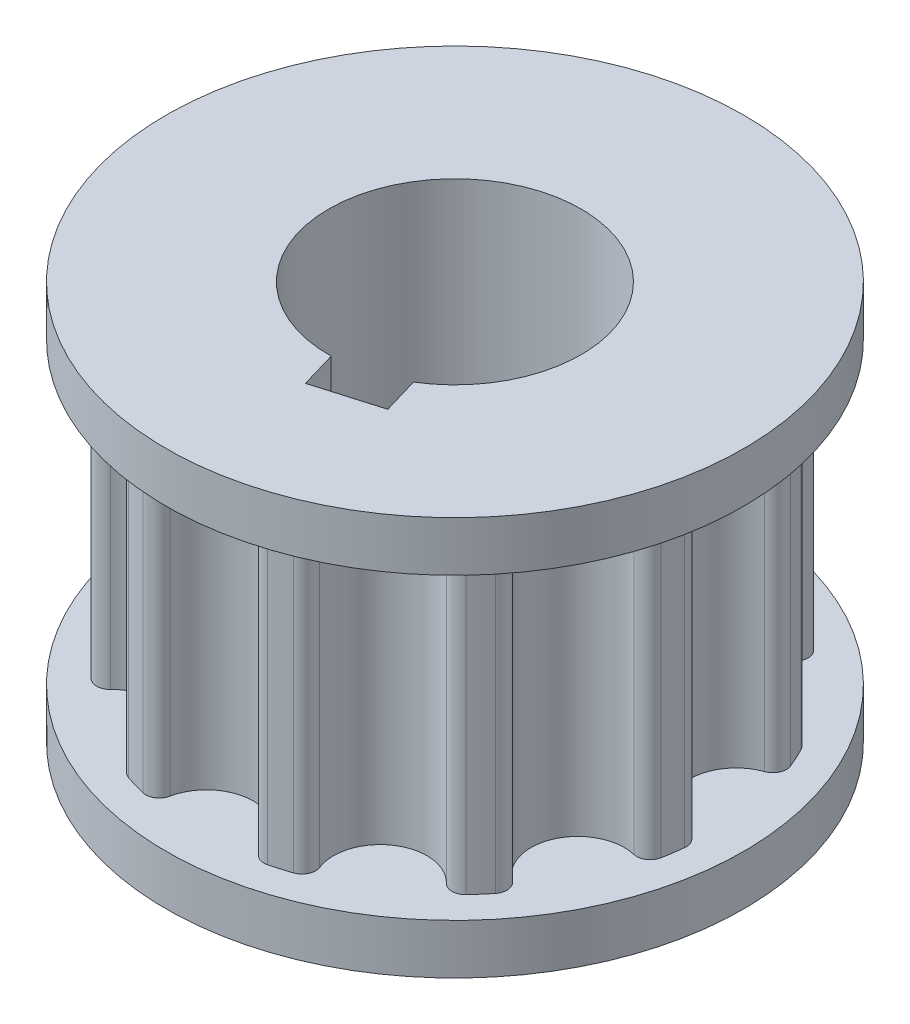
from build123d import *

# Parameters (mm, degrees)
SKETCH1_W           = 9.18202187
SKETCH1_H           = 1.5875
BOSS_EXTRUDE1_DEPTH = 9.5
SKETCH3_R           = 9.18202187
BOSS_EXTRUDE2_DEPTH = 1.5875
CUT_EXTRUDE1_DEPTH  = 13.67500005
SKETCH5_W           = 4.0132
SKETCH5_H           = 21.675
FILLET1_R           = 0.43


with BuildPart() as part:
    # Sketch1 → Revolve1 (revolve)
    with BuildSketch(Plane.XY):
        with Locations((4.591010935, 0.79375)):
            Rectangle(SKETCH1_W, SKETCH1_H)
    revolve(axis=Axis((0, 1.5875, 0), (0, -1, 0)))

    # Sketch2 → Boss-Extrude1 (add)
    with BuildSketch(Plane.XZ):
        with BuildLine():
            ThreePointArc((7.05074077, -4.151209038), (4.843320551, -4.196761147), (5.112380748, -6.388195752))
            ThreePointArc((5.112380748, -6.388195752), (4.423534992, -6.883154804), (3.687147534, -7.304137522))
            ThreePointArc((3.687147534, -7.304137522), (1.805520147, -6.149036924), (0.847088992, -8.138053952))
            ThreePointArc((0.847088992, -8.138053952), (0, -8.18202187), (-0.847088992, -8.138053952))
            ThreePointArc((-0.847088992, -8.138053952), (-1.805520147, -6.149036924), (-3.687147534, -7.304137522))
            ThreePointArc((-3.687147534, -7.304137522), (-4.423534992, -6.883154804), (-5.112380748, -6.388195752))
            ThreePointArc((-5.112380748, -6.388195752), (-4.843320551, -4.196761147), (-7.05074077, -4.151209038))
            ThreePointArc((-7.05074077, -4.151209038), (-7.44262888, -3.398934722), (-7.754527739, -2.610130538))
            ThreePointArc((-7.754527739, -2.610130538), (-6.343400902, -0.91204336), (-8.17577363, 0.319698985))
            ThreePointArc((-8.17577363, 0.319698985), (-8.098740685, 1.164423119), (-7.934666964, 1.996632679))
            ThreePointArc((-7.934666964, 1.996632679), (-5.829496286, 2.66224175), (-6.705056129, 4.689104839))
            ThreePointArc((-6.705056129, 4.689104839), (-6.183559546, 5.358084847), (-5.595605491, 5.969479129))
            ThreePointArc((-5.595605491, 5.969479129), (-3.464767789, 5.391283915), (-3.105530683, 7.569753038))
            ThreePointArc((-3.105530683, 7.569753038), (-2.305141942, 7.850592494), (-1.479978812, 8.047058133))
            ThreePointArc((-1.479978812, 8.047058133), (0, 6.40863153), (1.479978812, 8.047058133))
            ThreePointArc((1.479978812, 8.047058133), (2.305141942, 7.850592494), (3.105530683, 7.569753038))
            ThreePointArc((3.105530683, 7.569753038), (3.464767789, 5.391283915), (5.595605491, 5.969479129))
            ThreePointArc((5.595605491, 5.969479129), (6.183559546, 5.358084847), (6.705056129, 4.689104839))
            ThreePointArc((6.705056129, 4.689104839), (5.829496286, 2.66224175), (7.934666964, 1.996632679))
            ThreePointArc((7.934666964, 1.996632679), (8.098740685, 1.164423119), (8.17577363, 0.319698985))
            ThreePointArc((8.17577363, 0.319698985), (6.343400902, -0.91204336), (7.754527739, -2.610130538))
            ThreePointArc((7.754527739, -2.610130538), (7.44262888, -3.398934722), (7.05074077, -4.151209038))
        make_face()
    extrude(amount=BOSS_EXTRUDE1_DEPTH)

    # Sketch3 → Boss-Extrude2 (add)
    with BuildSketch(Plane(origin=(0, -9.50000005, 0), x_dir=(1, 0, 0), z_dir=(0, 1, 0))):
        Circle(SKETCH3_R)
    extrude(amount=-BOSS_EXTRUDE2_DEPTH)

    # Sketch4 → Cut-Extrude1 (cut, through all)
    with BuildSketch(Plane.XZ.offset(11.08750005)):
        with BuildLine():
            Line((2.442602932, 4.577250018), (0.419799845, 5.171198594))
            Line((0.419799845, 5.171198594), (0.079549259, 4.012411514))
            ThreePointArc((0.079549259, 4.012411514), (1.130649097, 3.850637202), (2.102352346, 3.418462937))
            Line((2.102352346, 3.418462937), (2.442602932, 4.577250018))
        make_face()
    extrude(amount=-CUT_EXTRUDE1_DEPTH, mode=Mode.SUBTRACT)

    # Sketch5 → Cut-Revolve1 (revolve, cut)
    with BuildSketch(Plane(origin=(0, 0, 0), x_dir=(-1, 0, 0), z_dir=(0, 0, -1))):
        with Locations((-2.0066, -9.25)):
            Rectangle(SKETCH5_W, SKETCH5_H)
    revolve(axis=Axis((0, -20.0875, 0), (0, 1, 0)), mode=Mode.SUBTRACT)

    # Fillet1
    fillet1_edges = [part.edges().sort_by_distance(p)[0] for p in [
        (7.05074077, -4.75, -4.151209038),
        (7.754527739, -4.75, -2.610130538),
        (8.17577363, -4.75, 0.319698985),
        (7.934666964, -4.75, 1.996632679),
        (6.705056129, -4.75, 4.689104839),
        (5.595605491, -4.75, 5.969479129),
        (3.105530683, -4.75, 7.569753038),
        (1.479978812, -4.75, 8.047058133),
        (-1.479978812, -4.75, 8.047058133),
        (-3.105530683, -4.75, 7.569753038),
        (-5.595605491, -4.75, 5.969479129),
        (-6.705056129, -4.75, 4.689104839),
        (-7.934666964, -4.75, 1.996632679),
        (-8.17577363, -4.75, 0.319698985),
        (-7.754527739, -4.75, -2.610130538),
        (-7.05074077, -4.75, -4.151209038),
        (-5.112380748, -4.75, -6.388195752),
        (-3.687147534, -4.75, -7.304137522),
        (-0.847088992, -4.75, -8.138053952),
        (0.847088992, -4.75, -8.138053952),
        (3.687147534, -4.75, -7.304137522),
        (5.112380748, -4.75, -6.388195752),
    ]]
    fillet(fillet1_edges, radius=FILLET1_R)


solid = part.part
